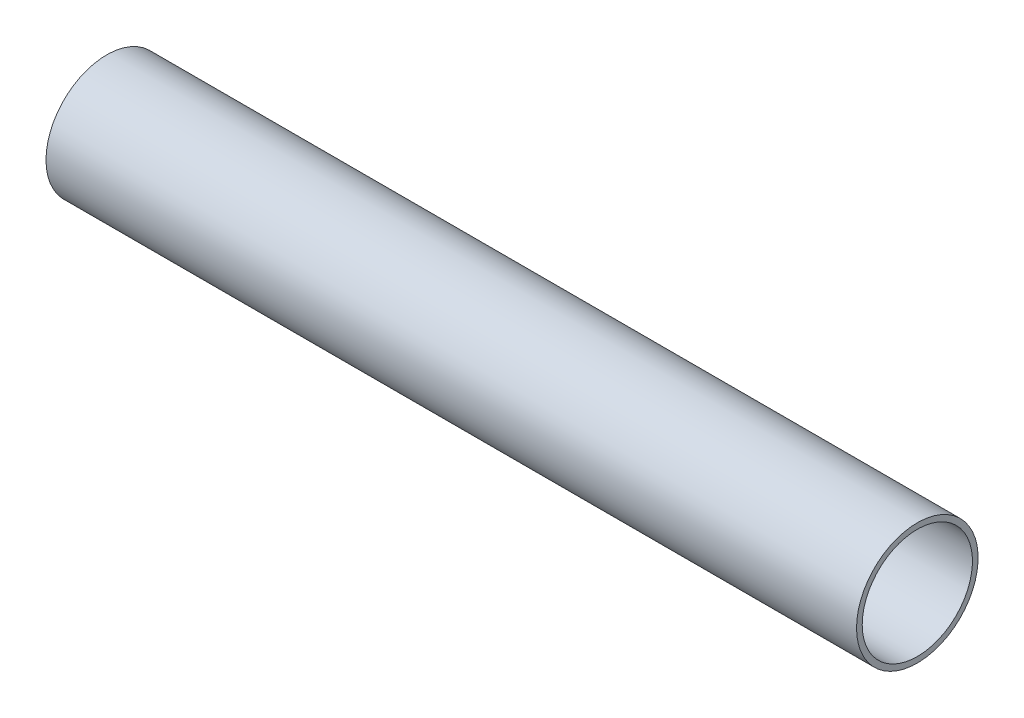
from build123d import *

# Parameters (mm, degrees)
SKETCH1_W = 127
SKETCH1_H = 0.889


with BuildPart() as part:
    # Sketch1 → Revolve1 (revolve)
    with BuildSketch(Plane(origin=(0, 0, 0), x_dir=(1, 0, 0), z_dir=(0, 1, 0))):
        with Locations((63.5, 9.0805)):
            Rectangle(SKETCH1_W, SKETCH1_H)
    revolve(axis=Axis((0, 0, 0), (1, 0, 0)))


solid = part.part
